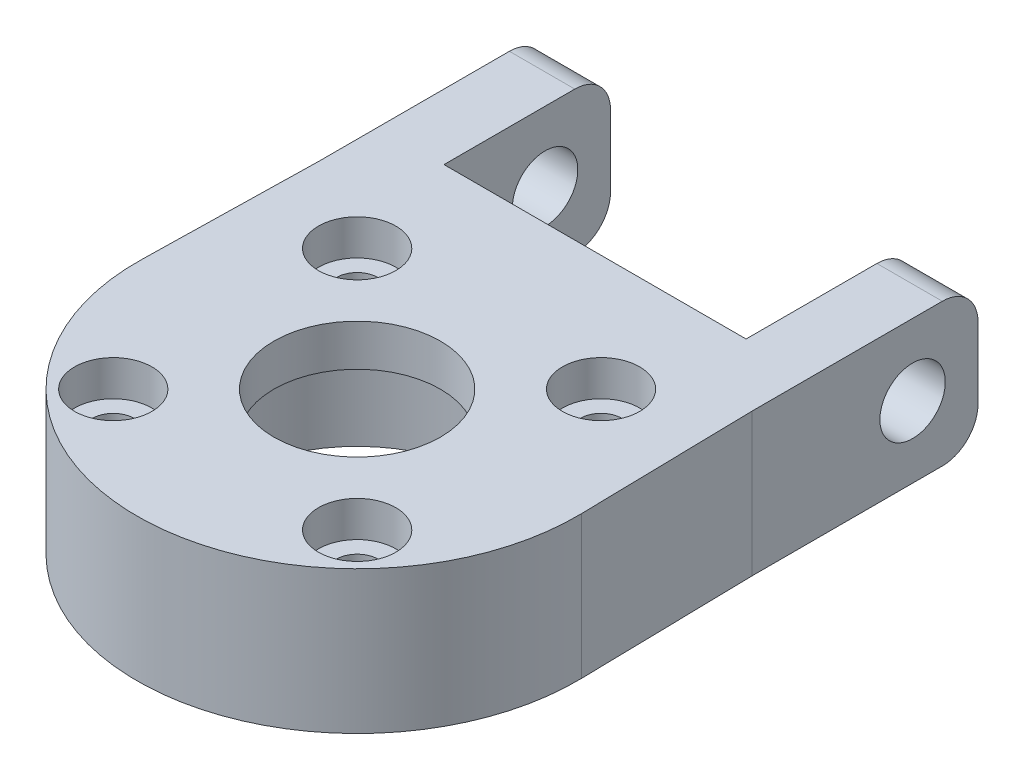
from build123d import *

# Parameters (mm, degrees)
SKETCH1_R           = 7
BOSS_EXTRUDE1_DEPTH = 12
SKETCH2_R           = 11.075
CUT_EXTRUDE1_DEPTH  = 8.5
SKETCH4_R           = 1.75
CUT_EXTRUDE4_DEPTH  = 13
SKETCH5_R           = 3.25
CUT_EXTRUDE5_DEPTH  = 3
SKETCH6_W           = 5.5
SKETCH6_H           = 12
BOSS_EXTRUDE2_DEPTH = 14
SKETCH7_R           = 2.75
CUT_EXTRUDE6_DEPTH  = 37.7
FILLET1_R           = 3


with BuildPart() as part:
    # Sketch1 → Boss-Extrude1 (new body)
    with BuildSketch(Plane(origin=(0, 0, 0), x_dir=(1, 0, 0), z_dir=(0, 1, 0))):
        with BuildLine():
            Line((-18.2, 15), (-18.2, 20))
            Line((-18.2, 20), (18.2, 20))
            Line((18.2, 20), (18.2, 15))
            Line((18.2, 15), (18.496206995, 0.374602179))
            ThreePointArc((18.496206995, 0.374602179), (0, -18.5), (-18.496206995, 0.374602179))
            Line((-18.496206995, 0.374602179), (-18.2, 15))
        make_face()
        Circle(SKETCH1_R, mode=Mode.SUBTRACT)
    extrude(amount=BOSS_EXTRUDE1_DEPTH)

    # Sketch2 → Cut-Extrude1 (cut)
    with BuildSketch(Plane.XZ):
        Circle(SKETCH2_R)
    extrude(amount=-CUT_EXTRUDE1_DEPTH, mode=Mode.SUBTRACT)

    # Sketch4 → Cut-Extrude4 (cut, through all)
    with BuildSketch(Plane.XZ):
        with Locations((10.253048327, 10.253048327)):
            Circle(SKETCH4_R)
        with Locations((10.253048327, -10.253048327)):
            Circle(SKETCH4_R)
        with Locations((-10.253048327, -10.253048327)):
            Circle(SKETCH4_R)
        with Locations((-10.253048327, 10.253048327)):
            Circle(SKETCH4_R)
    extrude(amount=-CUT_EXTRUDE4_DEPTH, mode=Mode.SUBTRACT)

    # Sketch5 → Cut-Extrude5 (cut)
    with BuildSketch(Plane(origin=(0, 12, 0), x_dir=(1, 0, 0), z_dir=(0, 1, 0))):
        with Locations((-10.253048327, 10.253048327)):
            Circle(SKETCH5_R)
        with Locations((10.253048327, 10.253048327)):
            Circle(SKETCH5_R)
        with Locations((10.253048327, -10.253048327)):
            Circle(SKETCH5_R)
        with Locations((-10.253048327, -10.253048327)):
            Circle(SKETCH5_R)
    extrude(amount=-CUT_EXTRUDE5_DEPTH, mode=Mode.SUBTRACT)

    # Sketch6 → Boss-Extrude2 (add)
    with BuildSketch(Plane(origin=(0, 0, -20), x_dir=(-1, 0, 0), z_dir=(0, 0, -1))):
        with Locations((-15.45, 6)):
            Rectangle(SKETCH6_W, SKETCH6_H)
        with Locations((15.45, 6)):
            Rectangle(SKETCH6_W, SKETCH6_H)
    extrude(amount=BOSS_EXTRUDE2_DEPTH)

    # Sketch7 → Cut-Extrude6 (cut, through all)
    with BuildSketch(Plane.ZY.offset(18.2)):
        with Locations((-28.501137854, 6)):
            Circle(SKETCH7_R)
    extrude(amount=-CUT_EXTRUDE6_DEPTH, mode=Mode.SUBTRACT)

    # Fillet1
    fillet1_edges = [part.edges().sort_by_distance(p)[0] for p in [
        (15.45, 0, -34),
        (15.45, 12, -34),
        (-15.45, 0, -34),
        (-15.45, 12, -34),
    ]]
    fillet(fillet1_edges, radius=FILLET1_R)


solid = part.part
